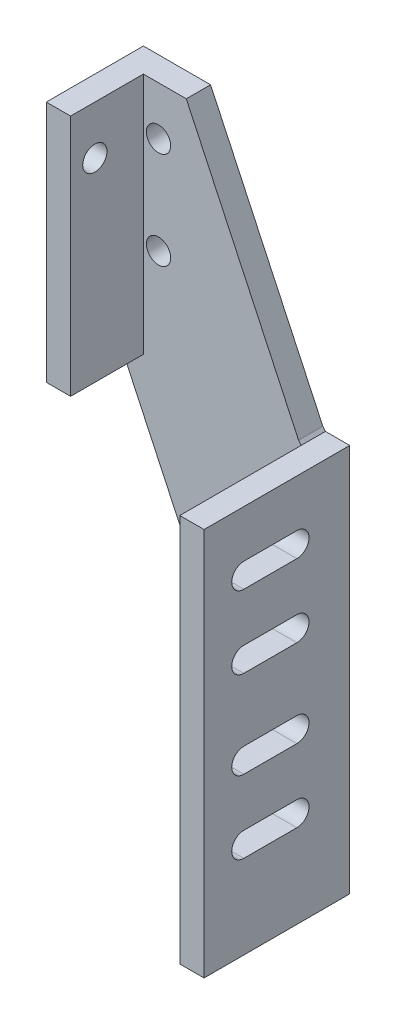
from build123d import *

# Parameters (mm, degrees)
EXTRUDE1_DEPTH          = 12.7
SKETCH2_W               = 12.7
SKETCH2_H               = 127
EXTRUDE2_DEPTH          = 38.1
SKETCH3_W               = 12.7
SKETCH3_H               = 203.2
EXTRUDE3_DEPTH          = 63.5
F_1_2_20_TAPPED_HOLE1_D = 12.7
F_1_2_20_TAPPED_HOLE2_D = 12.7
CUT_EXTRUDE1_REACH      = 109.933


with BuildPart() as part:
    # Sketch1 → Extrude1 (new body)
    with BuildSketch(Plane.XY):
        Polygon((1.34455174, -204.860398808), (1.34455174, -1.660398808), (-11.35544826, -1.660398808), (-12.7, 0), (-71.443804275, 125.347638028), (-106.588300915, 125.347638028), (-106.588300915, -1.652361972), (-11.35544826, -204.860398808), align=None)
    extrude(amount=EXTRUDE1_DEPTH)

    # Sketch2 → Extrude2 (add)
    with BuildSketch(Plane.XY.offset(12.7)):
        with Locations((-100.238300915, 61.847638028)):
            Rectangle(SKETCH2_W, SKETCH2_H)
    extrude(amount=EXTRUDE2_DEPTH)

    # Sketch3 → Extrude3 (add)
    with BuildSketch(Plane.XY.offset(12.7)):
        with Locations((-5.00544826, -103.260398808)):
            Rectangle(SKETCH3_W, SKETCH3_H)
    extrude(amount=EXTRUDE3_DEPTH)

    # 1/2-20 Tapped Hole1 (through all)
    with Locations(Plane(origin=(-106.588300915, 99.947638028, 38.1), x_dir=(0, -1, 0), z_dir=(-1, 0, 0))):
        with Locations((0, 0)):
            Hole(F_1_2_20_TAPPED_HOLE1_D / 2)

    # 1/2-20 Tapped Hole2 (through all)
    with Locations(Plane(origin=(-85.963500915, 99.947638028, 0), x_dir=(-1, 0, 0), z_dir=(0, 0, -1))):
        with Locations((0, 0), (0, -50.8)):
            Hole(F_1_2_20_TAPPED_HOLE2_D / 2)

    # Sketch6 → Cut-Extrude1 (cut, up to next)
    with BuildSketch(Plane(origin=(1.34455174, 0, 0), x_dir=(0, 0, -1), z_dir=(1, 0, 0)), mode=Mode.PRIVATE) as cut_extrude1_sk1:
        with BuildLine():
            Line((-55.372, -26.425398808), (-27.645063582, -26.425398808))
            ThreePointArc((-27.645063582, -26.425398808), (-21.295063582, -32.775398808), (-27.645063582, -39.125398808))
            Line((-27.645063582, -39.125398808), (-55.372, -39.125398808))
            ThreePointArc((-55.372, -39.125398808), (-61.722, -32.775398808), (-55.372, -26.425398808))
        make_face()
    cut_extrude1_tool1 = extrude(cut_extrude1_sk1.sketch, amount=-CUT_EXTRUDE1_REACH, mode=Mode.PRIVATE) & part.part
    add(cut_extrude1_tool1.solids().sort_by_distance((1.344552, -32.775399, 41.508532))[0], mode=Mode.SUBTRACT)
    # Sketch6 → Cut-Extrude1 (cut, up to next)
    with BuildSketch(Plane(origin=(1.34455174, 0, 0), x_dir=(0, 0, -1), z_dir=(1, 0, 0)), mode=Mode.PRIVATE) as cut_extrude1_sk2:
        with BuildLine():
            Line((-55.372, -64.525398808), (-27.645063582, -64.525398808))
            ThreePointArc((-27.645063582, -64.525398808), (-21.295063582, -70.875398808), (-27.645063582, -77.225398808))
            Line((-27.645063582, -77.225398808), (-55.372, -77.225398808))
            ThreePointArc((-55.372, -77.225398808), (-61.722, -70.875398808), (-55.372, -64.525398808))
        make_face()
    cut_extrude1_tool2 = extrude(cut_extrude1_sk2.sketch, amount=-CUT_EXTRUDE1_REACH, mode=Mode.PRIVATE) & part.part
    add(cut_extrude1_tool2.solids().sort_by_distance((1.344552, -70.875399, 41.508532))[0], mode=Mode.SUBTRACT)
    # Sketch6 → Cut-Extrude1 (cut, up to next)
    with BuildSketch(Plane(origin=(1.34455174, 0, 0), x_dir=(0, 0, -1), z_dir=(1, 0, 0)), mode=Mode.PRIVATE) as cut_extrude1_sk3:
        with BuildLine():
            Line((-55.372, -110.245398808), (-27.645063582, -110.245398808))
            ThreePointArc((-27.645063582, -110.245398808), (-21.295063582, -116.595398808), (-27.645063582, -122.945398808))
            Line((-27.645063582, -122.945398808), (-55.372, -122.945398808))
            ThreePointArc((-55.372, -122.945398808), (-61.722, -116.595398808), (-55.372, -110.245398808))
        make_face()
    cut_extrude1_tool3 = extrude(cut_extrude1_sk3.sketch, amount=-CUT_EXTRUDE1_REACH, mode=Mode.PRIVATE) & part.part
    add(cut_extrude1_tool3.solids().sort_by_distance((1.344552, -116.595399, 41.508532))[0], mode=Mode.SUBTRACT)
    # Sketch6 → Cut-Extrude1 (cut, up to next)
    with BuildSketch(Plane(origin=(1.34455174, 0, 0), x_dir=(0, 0, -1), z_dir=(1, 0, 0)), mode=Mode.PRIVATE) as cut_extrude1_sk4:
        with BuildLine():
            Line((-55.372, -148.345398808), (-27.645063582, -148.345398808))
            ThreePointArc((-27.645063582, -148.345398808), (-21.295063582, -154.695398808), (-27.645063582, -161.045398808))
            Line((-27.645063582, -161.045398808), (-55.372, -161.045398808))
            ThreePointArc((-55.372, -161.045398808), (-61.722, -154.695398808), (-55.372, -148.345398808))
        make_face()
    cut_extrude1_tool4 = extrude(cut_extrude1_sk4.sketch, amount=-CUT_EXTRUDE1_REACH, mode=Mode.PRIVATE) & part.part
    add(cut_extrude1_tool4.solids().sort_by_distance((1.344552, -154.695399, 41.508532))[0], mode=Mode.SUBTRACT)


solid = part.part
